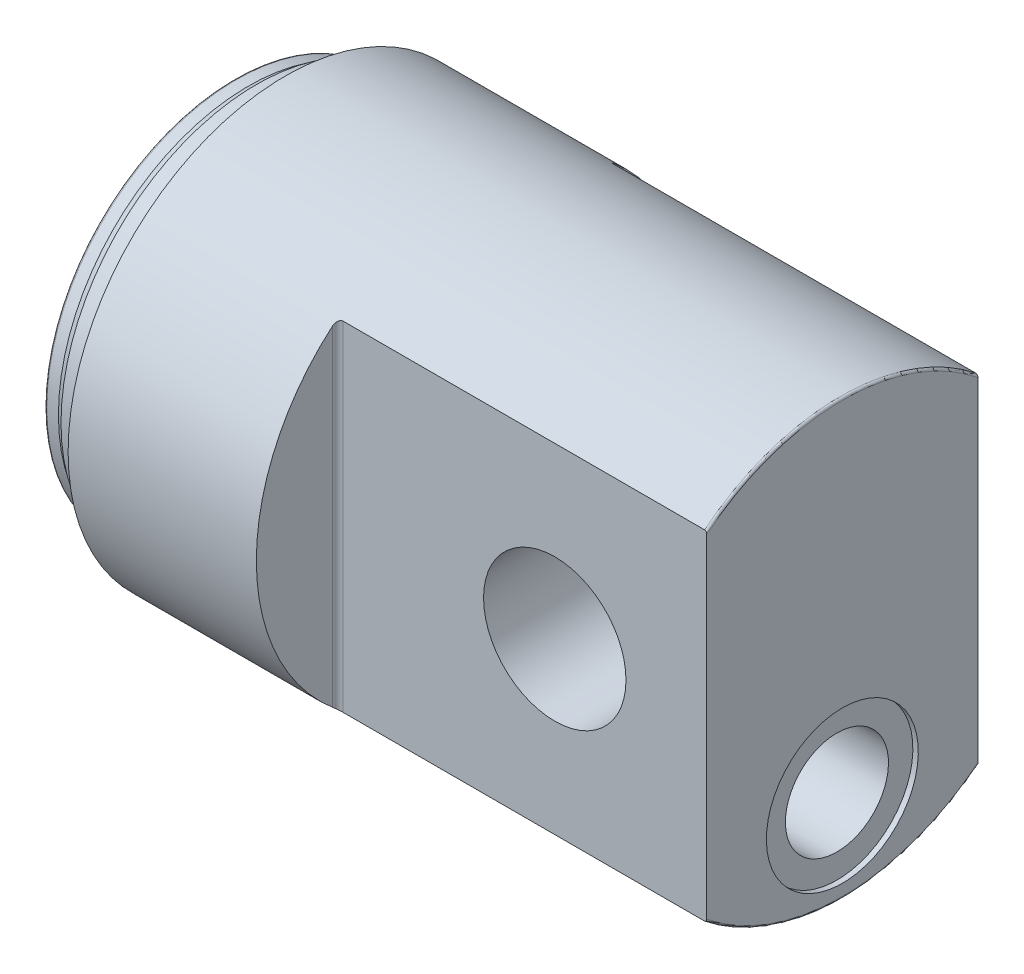
from build123d import *

# Parameters (mm, degrees)
SKETCH2_R            = 13.125
F_26_25_MM_HUL_DEPTH = 50
CUT_EXTRUDE1_DEPTH   = 50


with BuildPart() as part:
    # Sketch1 → Base-Revolve (revolve)
    with BuildSketch(Plane.XY):
        with BuildLine():
            Line((28, 0), (28, 39.6))
            ThreePointArc((28, 39.6), (27.882842712, 39.882842712), (27.6, 40))
            Line((27.6, 40), (-74.690598923, 40))
            Line((-74.690598923, 40), (-77, 36))
            Line((-77, 36), (-80, 36))
            Line((-80, 36), (-80, 34.9))
            ThreePointArc((-80, 34.9), (-80.191000574, 34.558943934), (-80.5815962, 34.54359739))
            Line((-80.5815962, 34.54359739), (-81.477336756, 35))
            Line((-81.477336756, 35), (-83.6, 35))
            ThreePointArc((-83.6, 35), (-83.882842712, 34.882842712), (-84, 34.6))
            Line((-84, 34.6), (-84, 25))
            Line((-84, 25), (-47, 25))
            Line((-47, 25), (-32.56624327, 0))
            Line((-32.56624327, 0), (28, 0))
        make_face()
    revolve(axis=Axis((-90.573458716, 0, 0), (1, 0, 0)))

    # Sketch2 → ø26.25 mm hul (cut, symmetric)
    with BuildSketch(Plane.XY):
        Circle(SKETCH2_R)
    extrude(amount=F_26_25_MM_HUL_DEPTH, both=True, mode=Mode.SUBTRACT)

    # Sketch3 → Cut-Extrude1 (cut, symmetric)
    with BuildSketch(Plane(origin=(0, 0, 0), x_dir=(1, 0, 0), z_dir=(0, 1, 0))):
        with BuildLine():
            Line((28, 25), (-39, 25))
            ThreePointArc((-39, 25), (-39.707106781, 25.292893219), (-40, 26))
            Line((-40, 26), (-40, 40))
            Line((-40, 40), (28, 40))
            Line((28, 40), (28, 25))
        make_face()
        with BuildLine():
            Line((-40, -26), (-40, -40))
            Line((-40, -40), (28, -40))
            Line((28, -40), (28, -25))
            Line((28, -25), (-39, -25))
            ThreePointArc((-39, -25), (-39.707106781, -25.292893219), (-40, -26))
        make_face()
    extrude(amount=CUT_EXTRUDE1_DEPTH, both=True, mode=Mode.SUBTRACT)

    # Sketch4 → Cut-Revolve1 (revolve, cut)
    with BuildSketch(Plane.XY):
        Polygon((28, -9.5), (27, -9.5), (27, -14), (8, -14), (6.267949192, -17), (-52, -17), (-55.75277675, -23.5), (28, -23.5), align=None)
    revolve(axis=Axis((28, -23.5, 0), (-1, 0, 0)), mode=Mode.SUBTRACT)


solid = part.part
